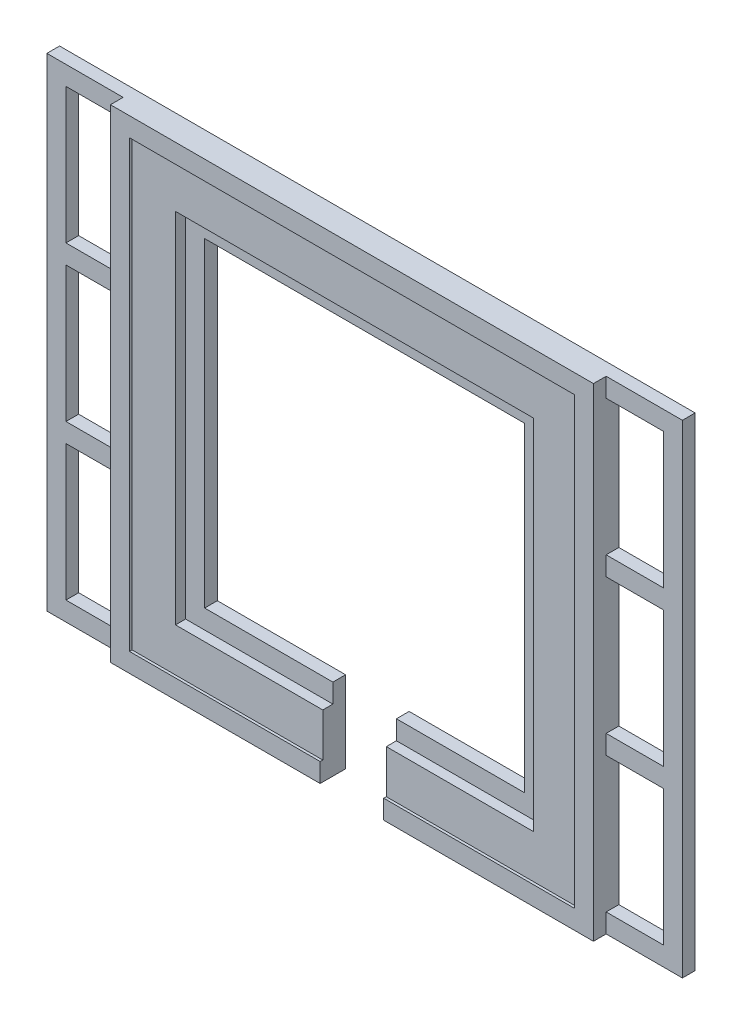
from build123d import *

# Parameters (mm, degrees)
SKETCH1_W           = 9
SKETCH1_H           = 21.333333333
SKETCH1_H_2         = 21.333333334
BOSS_EXTRUDE1_DEPTH = 2
BOSS_EXTRUDE2_DEPTH = 3.59
BOSS_EXTRUDE3_DEPTH = 4


with BuildPart() as part:
    # Sketch1 → Boss-Extrude1 (new body)
    with BuildSketch(Plane.XY):
        Polygon((0, 76), (0, 0), (45, 0), (45, 12.825), (24.825, 12.825), (24.825, 63.175), (75.175, 63.175), (75.175, 12.825), (55, 12.825), (55, 0), (100, 0), (100, 76), align=None)
        with Locations((7.5, 62.333333334)):
            Rectangle(SKETCH1_W, SKETCH1_H, mode=Mode.SUBTRACT)
        with Locations((7.5, 38)):
            Rectangle(SKETCH1_W, SKETCH1_H_2, mode=Mode.SUBTRACT)
        with Locations((7.5, 13.666666667)):
            Rectangle(SKETCH1_W, SKETCH1_H, mode=Mode.SUBTRACT)
        with Locations((92.5, 62.333333334)):
            Rectangle(SKETCH1_W, SKETCH1_H, mode=Mode.SUBTRACT)
        with Locations((92.5, 38)):
            Rectangle(SKETCH1_W, SKETCH1_H_2, mode=Mode.SUBTRACT)
        with Locations((92.5, 13.666666667)):
            Rectangle(SKETCH1_W, SKETCH1_H, mode=Mode.SUBTRACT)
    extrude(amount=BOSS_EXTRUDE1_DEPTH)

    # Sketch1_3 → Boss-Extrude2 (add)
    with BuildSketch(Plane.XY):
        Polygon((15, 3), (45, 3), (45, 9.825), (21.825, 9.825), (21.825, 66.175), (78.175, 66.175), (78.175, 9.825), (55, 9.825), (55, 3), (85, 3), (85, 73), (15, 73), align=None)
    extrude(amount=BOSS_EXTRUDE2_DEPTH)

    # Sketch1_4 → Boss-Extrude3 (add)
    with BuildSketch(Plane.XY):
        Polygon((12, 3), (12, 0), (45, 0), (45, 3), (15, 3), (15, 73), (85, 73), (85, 3), (55, 3), (55, 0), (88, 0), (88, 3), (88, 24.333333333), (88, 27.333333333), (88, 48.666666667), (88, 51.666666667), (88, 73), (88, 76), (12, 76), (12, 73), (12, 51.666666667), (12, 48.666666667), (12, 27.333333333), (12, 24.333333333), align=None)
    extrude(amount=BOSS_EXTRUDE3_DEPTH)


solid = part.part
